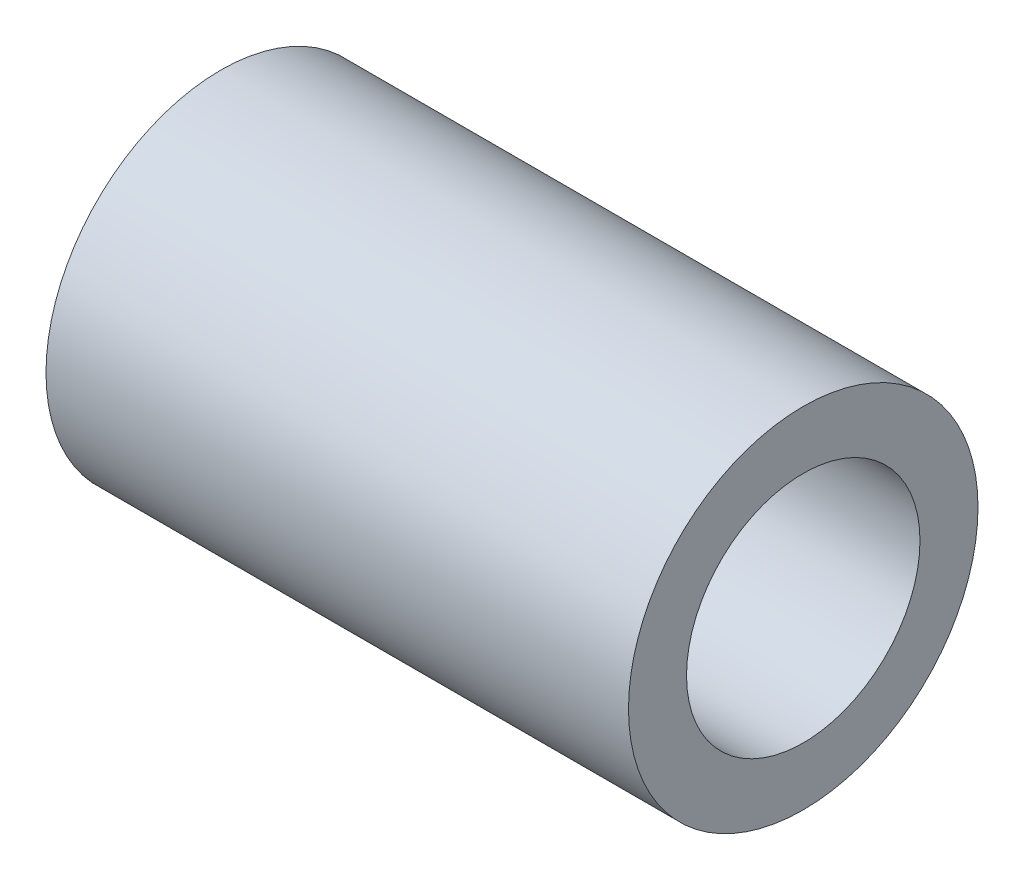
from build123d import *

# Parameters (mm, degrees)
SKETCH1_W = 31.75
SKETCH1_H = 3.1623


with BuildPart() as part:
    # Sketch1 → Revolve1 (revolve)
    with BuildSketch(Plane.XY):
        with Locations((15.875, 7.94385)):
            Rectangle(SKETCH1_W, SKETCH1_H)
    revolve(axis=Axis((0, 0, 0), (1, 0, 0)))


solid = part.part
